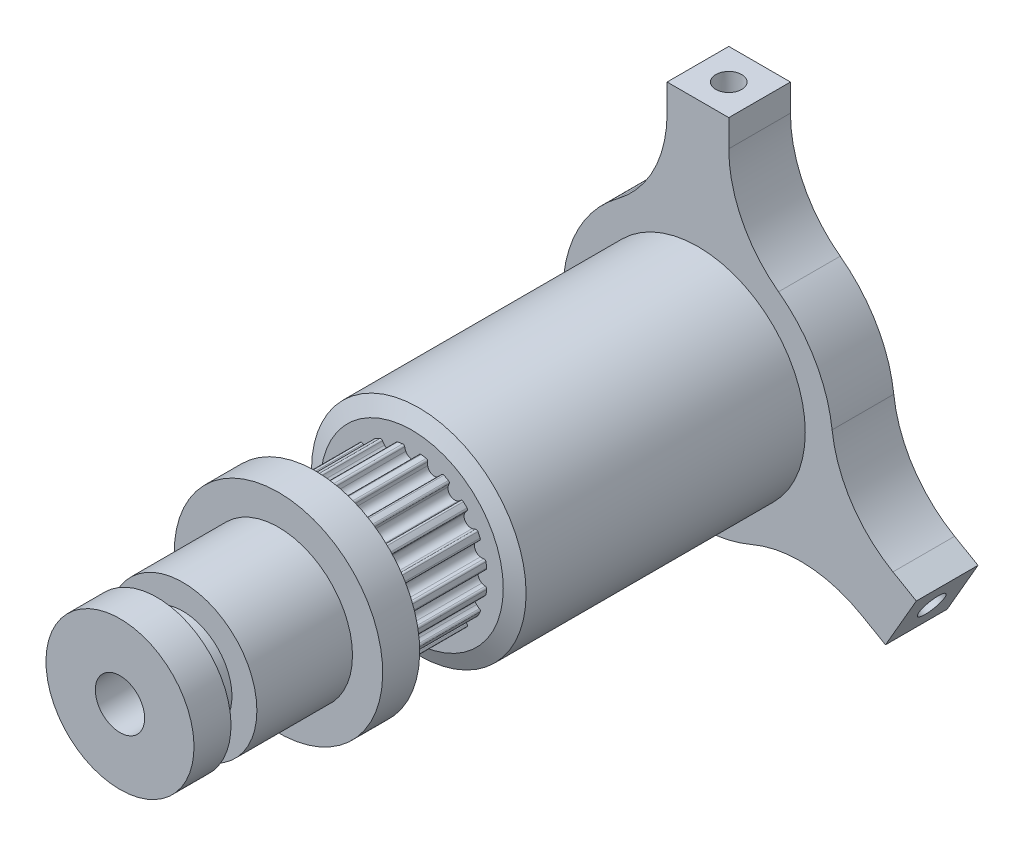
from build123d import *
from build123d.topology import SkipClean

# Parameters (mm, degrees)
BOSS_EXTRUDE1_DEPTH = 5
SKETCH11_R          = 6
BOSS_EXTRUDE3_DEPTH = 7.75
SKETCH2_R           = 1.05
CUT_EXTRUDE1_DEPTH  = 10
CIRPATTERN2_COUNT   = 3
DRAFT4_ANGLE        = 1
DRAFT5_ANGLE        = 1
DRAFT6_ANGLE        = 1
SKETCH3_R           = 2
CUT_EXTRUDE2_DEPTH  = 58.995874426
CUT_EXTRUDE3_DEPTH  = 7.37
CIRPATTERN4_COUNT   = 20
FILLET1_R           = 10


with BuildPart() as part:
    # Sketch1 → Boss-Extrude1 (new body)
    with BuildSketch(Plane.XY):
        with BuildLine():
            Line((7.982517262, -7.495459836), (15.204482672, -11.665063509))
            Line((15.204482672, -11.665063509), (17.704482672, -7.334936491))
            Line((17.704482672, -7.334936491), (10.482517262, -3.165332817))
            ThreePointArc((10.482517262, -3.165332817), (9.482978171, 5.475), (2.5, 10.660792653))
            Line((2.5, 10.660792653), (2.5, 19))
            Line((2.5, 19), (-2.5, 19))
            Line((-2.5, 19), (-2.5, 10.660792653))
            ThreePointArc((-2.5, 10.660792653), (-9.482978171, 5.475), (-10.482517262, -3.165332817))
            Line((-10.482517262, -3.165332817), (-17.704482672, -7.334936491))
            Line((-17.704482672, -7.334936491), (-15.204482672, -11.665063509))
            Line((-15.204482672, -11.665063509), (-7.982517262, -7.495459836))
            ThreePointArc((-7.982517262, -7.495459836), (0, -10.95), (7.982517262, -7.495459836))
        make_face()
    extrude(amount=BOSS_EXTRUDE1_DEPTH)

    # main_revolve_sketch → main_revolve (revolve)
    with BuildSketch(Plane(origin=(0, 0, 0), x_dir=(0, 0, -1), z_dir=(1, 0, 0))):
        Polygon((-5, 0), (-5, 8.7), (-27.63, 8.7), (-28.186842864, 7.404), (-28.186842864, 6.1085), (-35.556842864, 6.1085), (-35.556842864, 7.404), (-36.006270053, 8.45), (-39.006270053, 8.45), (-39.006270053, 0), align=None)
    revolve(axis=Axis((0, 0, 5), (0, 0, 1)))

    # Sketch11 → Boss-Extrude3 (add)
    with BuildSketch(Plane.XY.offset(39.006270053)):
        Circle(SKETCH11_R)
    extrude(amount=BOSS_EXTRUDE3_DEPTH)

    # Sketch13 → Revolve2 (revolve)
    with BuildSketch(Plane(origin=(0, 0, 0), x_dir=(0, 0, -1), z_dir=(1, 0, 0)), mode=Mode.PRIVATE) as revolve2_sk:
        Polygon((-46.756270053, 0), (-46.756270053, 3.9775), (-48.856270053, 3.9775), (-48.856270053, 6), (-51.856270053, 6), (-51.856270053, 0), align=None)
    revolve(revolve2_sk.sketch.rotate(Axis((0, 0, 51.856270053), (0, 0, -1)), 180), axis=Axis((0, 0, 51.856270053), (0, 0, -1)))

    # Sketch2 → Cut-Extrude1 (cut)
    with BuildSketch(Plane(origin=(0, 19, 0), x_dir=(1, 0, 0), z_dir=(0, 1, 0))):
        with Locations(Location((0, -2.5, 0), (0, 0, 270))):
            Circle(SKETCH2_R)
    cut_extrude1 = extrude(amount=-CUT_EXTRUDE1_DEPTH, mode=Mode.SUBTRACT)

    # CirPattern2: Cut-Extrude1 ×3 about axis
    cirpattern2_axis = Axis((0, 0, 0), (0, 0, 1))
    for i in range(1, CIRPATTERN2_COUNT):
        add(cut_extrude1.rotate(cirpattern2_axis, i * 360 / CIRPATTERN2_COUNT), mode=Mode.SUBTRACT)

    # Draft4
    draft4_faces = [part.faces().sort_by_distance(p)[0] for p in [
        (0, 14, 1.45),
    ]]
    draft(draft4_faces, Plane(origin=(-2.5, 19, 5), x_dir=(0, 0, 1), z_dir=(0, 1, 0)), DRAFT4_ANGLE)

    # Draft5
    draft5_faces = [part.faces().sort_by_distance(p)[0] for p in [
        (-12.124355653, -7, 1.45),
    ]]
    draft(draft5_faces, Plane(origin=(-17.704482672, -7.334936491, 5), x_dir=(0.4999999999999998, -0.8660254037844388, 0), z_dir=(-0.8660254037844388, -0.4999999999999998, 0)), DRAFT5_ANGLE)

    # Draft6
    draft6_faces = [part.faces().sort_by_distance(p)[0] for p in [
        (12.124355653, -7, 1.45),
    ]]
    draft(draft6_faces, Plane(origin=(15.204482672, -11.665063509, 5), x_dir=(0.4999999999999998, 0.8660254037844388, 0), z_dir=(0.8660254037844388, -0.4999999999999998, 0)), DRAFT6_ANGLE)

    # Sketch3 → Cut-Extrude2 (cut, through all)
    with BuildSketch(Plane(origin=(0, 0, 0), x_dir=(-1, 0, 0), z_dir=(0, 0, -1))):
        Circle(SKETCH3_R)
    extrude(amount=-CUT_EXTRUDE2_DEPTH, mode=Mode.SUBTRACT)

    # Sketch7 → Cut-Extrude3 (cut)
    with SkipClean():  # the faces are left unmerged after this step: merging them gives an invalid solid
        with BuildSketch(Plane.XY.offset(28.186842864)):
            with BuildLine():
                Line((-1.896292335, 5.806707124), (-2.840989707, 8.6995))
                Line((-2.840989707, 8.6995), (2.840989707, 8.6995))
                Line((2.840989707, 8.6995), (1.896292335, 5.806707124))
                ThreePointArc((1.896292335, 5.806707124), (1.330166224, 5.961914966), (0.751756185, 6.062065233))
                ThreePointArc((0.751756185, 6.062065233), (0.643911332, 6.033664451), (0.58547487, 5.93867868))
                ThreePointArc((0.58547487, 5.93867868), (0.551683777, 5.801420225), (0.498876404, 5.670297753))
                ThreePointArc((0.498876404, 5.670297753), (0, 5.3585), (-0.498876404, 5.670297753))
                ThreePointArc((-0.498876404, 5.670297753), (-0.551683777, 5.801420225), (-0.58547487, 5.93867868))
                ThreePointArc((-0.58547487, 5.93867868), (-0.643911332, 6.033664451), (-0.751756185, 6.062065233))
                ThreePointArc((-0.751756185, 6.062065233), (-1.330166224, 5.961914966), (-1.896292335, 5.806707124))
            make_face()
        cut_extrude3 = extrude(amount=CUT_EXTRUDE3_DEPTH, mode=Mode.SUBTRACT)

    # CirPattern4: Cut-Extrude3 ×20 about axis
    with SkipClean():  # the faces are left unmerged after this step: merging them gives an invalid solid
        cirpattern4_axis = Axis((0, 0, 0), (0, 0, 1))
        for i in range(1, CIRPATTERN4_COUNT):
            add(cut_extrude3.rotate(cirpattern4_axis, i * 360 / CIRPATTERN4_COUNT), mode=Mode.SUBTRACT)

    # Fillet1
    fillet1_edges = [part.edges().sort_by_distance(p)[0] for p in [
        (-2.5, 10.660792653, 2.5),
        (2.5, 10.660792653, 2.5),
        (10.482517262, -3.165332817, 2.5),
        (7.982517262, -7.495459836, 2.5),
        (-7.982517262, -7.495459836, 2.5),
        (-10.482517262, -3.165332817, 2.5),
    ]]
    fillet(fillet1_edges, radius=FILLET1_R)


solid = part.part
